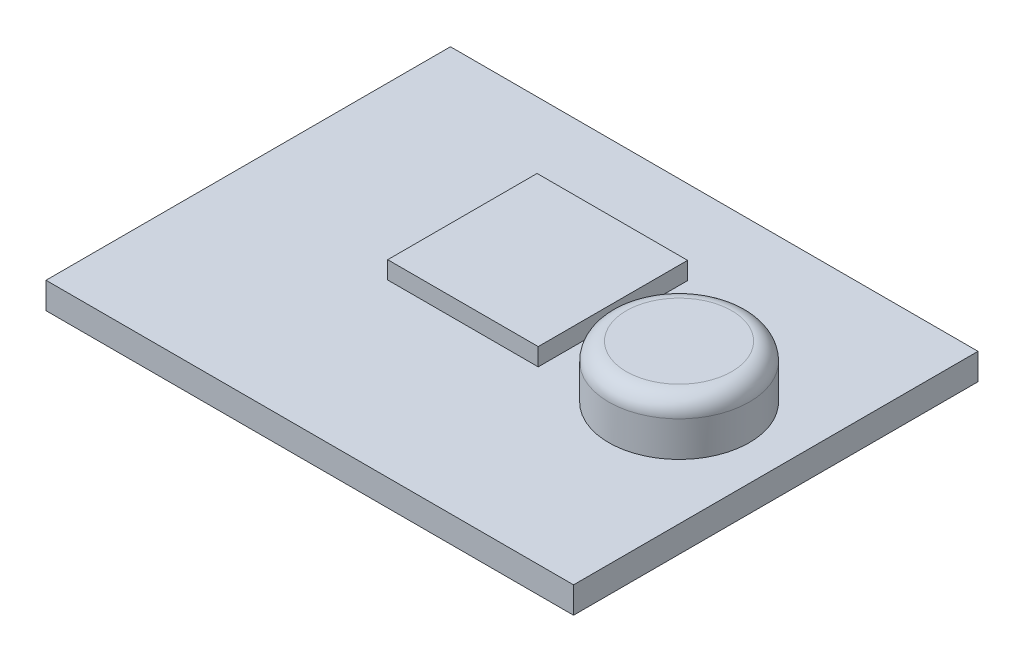
from build123d import *

# Parameters (mm, degrees)
ESBO_O1_W                = 30
ESBO_O1_H                = 23
RESSALTO_EXTRUS_O1_DEPTH = 1.5
ESBO_O2_W                = 8.558282237
ESBO_O2_H                = 8.494651886
RESSALTO_EXTRUS_O2_DEPTH = 1
ESBO_O3_R                = 4
RESSALTO_EXTRUS_O3_DEPTH = 3
FILETE1_R                = 1


with BuildPart() as part:
    # Esboço1 → Ressalto-extrusão1 (new body)
    with BuildSketch(Plane(origin=(0, 0, 0), x_dir=(1, 0, 0), z_dir=(0, 1, 0))):
        with Locations((15, 11.5)):
            Rectangle(ESBO_O1_W, ESBO_O1_H)
    extrude(amount=RESSALTO_EXTRUS_O1_DEPTH)

    # Esboço2 → Ressalto-extrusão2 (add)
    with BuildSketch(Plane(origin=(0, 1.5, 0), x_dir=(-1, 0, 0), z_dir=(0, 1, 0))):
        with Locations((-13.983300564, -13.975214048)):
            Rectangle(ESBO_O2_W, ESBO_O2_H)
    extrude(amount=RESSALTO_EXTRUS_O2_DEPTH)

    # Esboço3 → Ressalto-extrusão3 (add)
    with BuildSketch(Plane(origin=(0, 1.5, 0), x_dir=(1, 0, 0), z_dir=(0, 1, 0))):
        with Locations((24, 12)):
            Circle(ESBO_O3_R)
    extrude(amount=RESSALTO_EXTRUS_O3_DEPTH)

    # Filete1
    filete1_edges = [part.edges().sort_by_distance(p)[0] for p in [
        (20, 4.5, -12),
    ]]
    fillet(filete1_edges, radius=FILETE1_R)


solid = part.part
